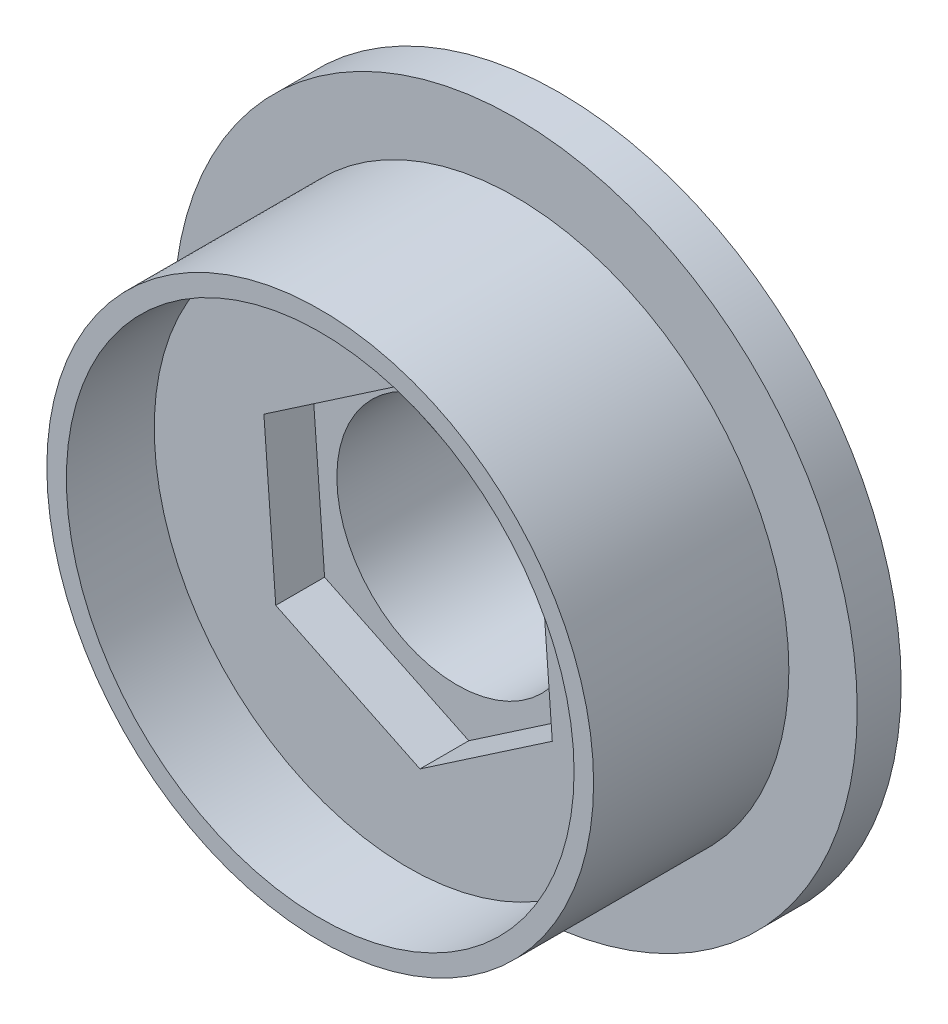
from build123d import *

# Parameters (mm, degrees)
CUT_EXTRUDE2_DEPTH = 7
SKETCH2_R          = 13
CUT_EXTRUDE1_DEPTH = 4.5


with BuildPart() as part:
    # Sketch1 → Revolve1 (revolve)
    with BuildSketch(Plane(origin=(0, 0, 0), x_dir=(1, 0, 0), z_dir=(0, 1, 0))):
        with BuildLine():
            Line((6.15, -14.25), (6.15, 0))
            Line((6.15, 0), (8, 0))
            ThreePointArc((8, 0), (12.85412196, -0.505420691), (17.5, -2))
            Line((17.5, -2), (17.5, -4.25))
            Line((17.5, -4.25), (14, -4.25))
            Line((14, -4.25), (14, -14.25))
            Line((14, -14.25), (6.15, -14.25))
        make_face()
    revolve(axis=Axis((0, 0, 0), (0, 0, 1)))

    # Sketch3 → Cut-Extrude2 (cut)
    with BuildSketch(Plane.XY.offset(14.25)):
        Polygon((0.608498328, -8.31690962), (7.38466563, -3.702054257), (6.776167302, 4.473706449), (-0.608498328, 8.034611791), (-7.38466563, 3.419756428), (-6.776167302, -4.756004278), align=None)
    extrude(amount=-CUT_EXTRUDE2_DEPTH, mode=Mode.SUBTRACT)

    # Sketch2 → Cut-Extrude1 (cut)
    with BuildSketch(Plane.XY.offset(14.25)):
        Circle(SKETCH2_R)
    extrude(amount=-CUT_EXTRUDE1_DEPTH, mode=Mode.SUBTRACT)


solid = part.part
